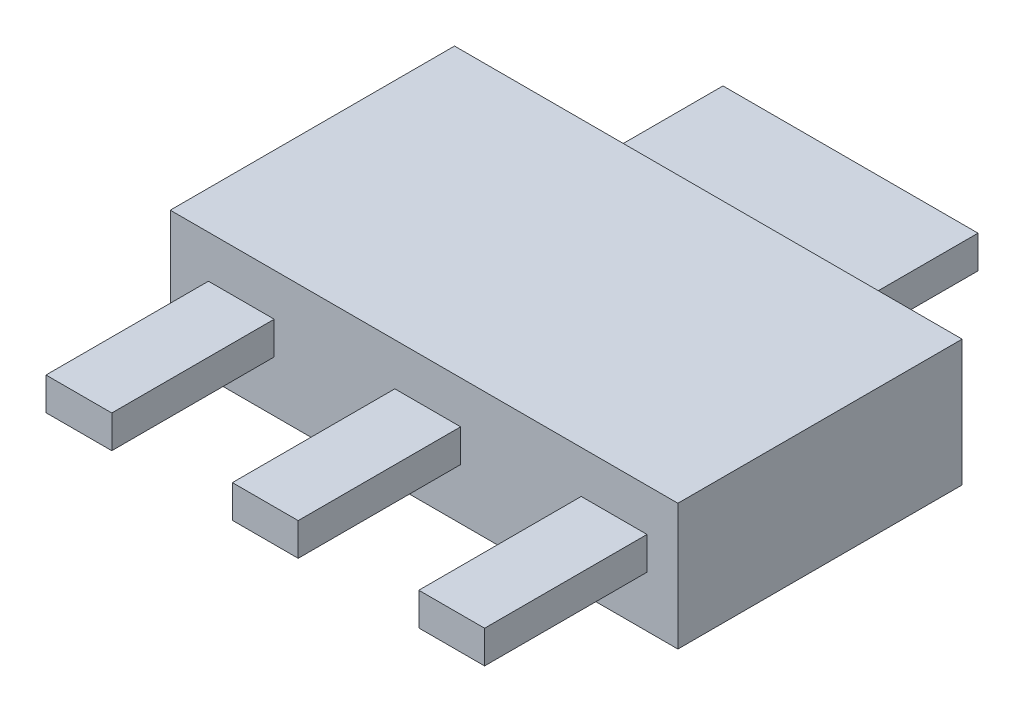
from build123d import *

# Parameters (mm, degrees)
SKETCH1_W             = 6.25
SKETCH1_H             = 3.5
BOSS_EXTRUDE1_DEPTH   = 1.555
SKETCH2_W             = 0.81
SKETCH2_H             = 0.4025
BOSS_EXTRUDE8_DEPTH   = 2
BOSS_EXTRUDE8_2_DEPTH = 2
BOSS_EXTRUDE8_3_DEPTH = 2
SKETCH7_W             = 3.14
SKETCH7_H             = 0.4025
BOSS_EXTRUDE9_DEPTH   = 1.75


with BuildPart() as part:
    # Sketch1 → Boss-Extrude1 (new body)
    with BuildSketch(Plane(origin=(0, 0, 0), x_dir=(1, 0, 0), z_dir=(0, 1, 0))):
        with Locations((3.125, 1.75)):
            Rectangle(SKETCH1_W, SKETCH1_H)
    extrude(amount=BOSS_EXTRUDE1_DEPTH)

    # Sketch7 → Boss-Extrude9 (add)
    with BuildSketch(Plane(origin=(0, 0, -3.5), x_dir=(-1, 0, 0), z_dir=(0, 0, -1))):
        with Locations((-3.125, 0.83125)):
            Rectangle(SKETCH7_W, SKETCH7_H)
    extrude(amount=BOSS_EXTRUDE9_DEPTH)


with BuildPart() as body_2:
    # Sketch2 → Boss-Extrude8 (new body)
    with BuildSketch(Plane.XY):
        with Locations((0.875, 0.83125)):
            Rectangle(SKETCH2_W, SKETCH2_H)
    extrude(amount=BOSS_EXTRUDE8_DEPTH)


with BuildPart() as body_3:
    # Sketch2 → Boss-Extrude8 2 (new body)
    with BuildSketch(Plane.XY):
        with Locations((3.17, 0.83125)):
            Rectangle(SKETCH2_W, SKETCH2_H)
    extrude(amount=BOSS_EXTRUDE8_2_DEPTH)


with BuildPart() as body_4:
    # Sketch2 → Boss-Extrude8 3 (new body)
    with BuildSketch(Plane.XY):
        with Locations((5.465, 0.83125)):
            Rectangle(SKETCH2_W, SKETCH2_H)
    extrude(amount=BOSS_EXTRUDE8_3_DEPTH)


solid = Compound([part.part, body_2.part, body_3.part, body_4.part])
